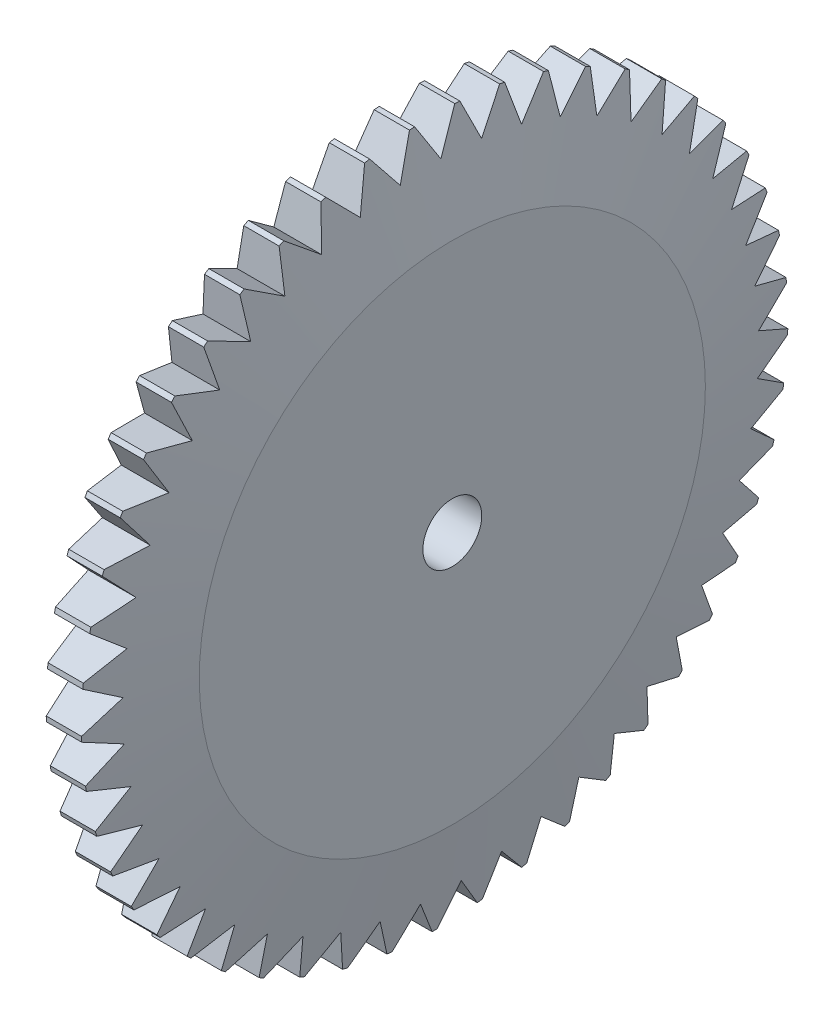
from build123d import *

# Parameters (mm, degrees)
SKETCH1_R           = 60
SKETCH1_R_2         = 5
BOSS_EXTRUDE1_DEPTH = 6
CHAMFER2_SIZE       = 3
CHAMFER2_SIZE2      = 17.013845459
CHAMFER3_SIZE       = 3
CHAMFER3_SIZE2      = 17.013845459
CUT_EXTRUDE2_DEPTH  = 12
CIRPATTERN2_COUNT   = 49


with BuildPart() as part:
    # Sketch1 → Boss-Extrude1 (new body, symmetric)
    with BuildSketch(Plane(origin=(0, 0, 0), x_dir=(0, 0, -1), z_dir=(1, 0, 0))):
        Circle(SKETCH1_R)
        Circle(SKETCH1_R_2, mode=Mode.SUBTRACT)
    extrude(amount=BOSS_EXTRUDE1_DEPTH, both=True)

    # Chamfer2
    chamfer2_edges = [part.edges().sort_by_distance(p)[0] for p in [
        (6, 0, 60),
    ]]
    chamfer2_side = [part.faces().sort_by_distance(p)[0] for p in [
        (0, 0, 60),
    ]]
    chamfer(chamfer2_edges, length=CHAMFER2_SIZE, length2=CHAMFER2_SIZE2, reference=chamfer2_side[0])

    # Chamfer3
    chamfer3_edges = [part.edges().sort_by_distance(p)[0] for p in [
        (-6, 0, 60),
    ]]
    chamfer3_side = [part.faces().sort_by_distance(p)[0] for p in [
        (-1.5, 0, 60),
    ]]
    chamfer(chamfer3_edges, length=CHAMFER3_SIZE, length2=CHAMFER3_SIZE2, reference=chamfer3_side[0])

    # Sketch2 → Cut-Extrude2 (cut)
    with BuildSketch(Plane(origin=(6, 0, 0), x_dir=(0, 0, -1), z_dir=(1, 0, 0))):
        with BuildLine():
            Line((0, 54), (3.408170747, 59.903124895))
            ThreePointArc((3.408170747, 59.903124895), (0, 60.816341494), (-3.408170747, 59.903124895))
            Line((-3.408170747, 59.903124895), (0, 54))
        make_face()
    cut_extrude2 = extrude(amount=-CUT_EXTRUDE2_DEPTH, mode=Mode.SUBTRACT)

    # CirPattern2: Cut-Extrude2 ×49 about axis
    cirpattern2_axis = Axis((0, 0, 0), (1, 0, 0))
    for i in range(1, CIRPATTERN2_COUNT):
        add(cut_extrude2.rotate(cirpattern2_axis, i * 360 / CIRPATTERN2_COUNT), mode=Mode.SUBTRACT)


solid = part.part
